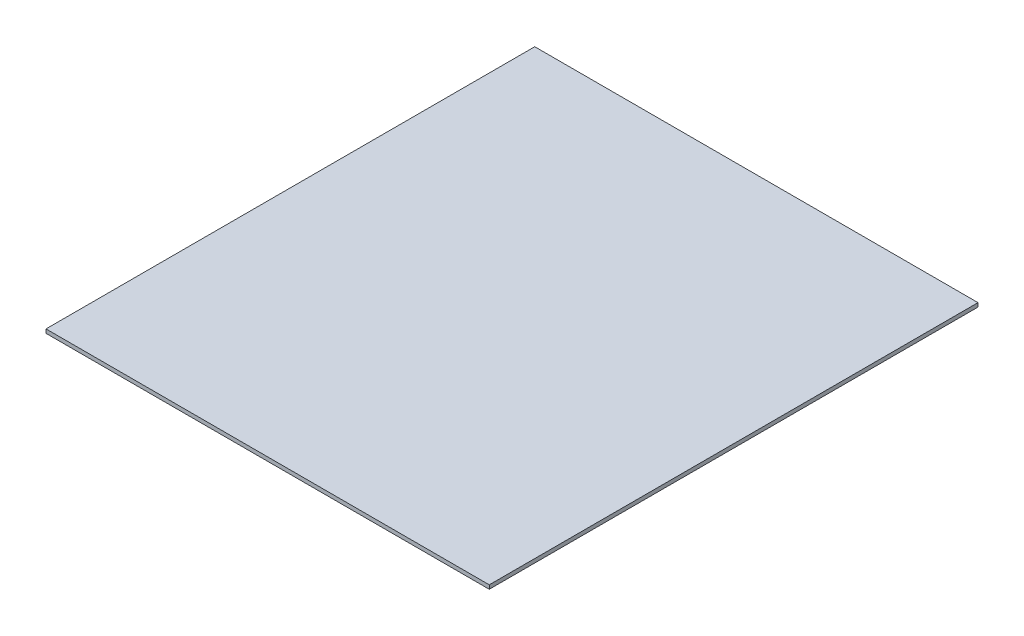
from build123d import *

# Parameters (mm, degrees)
SKETCH1_W           = 458
SKETCH1_H           = 505
BOSS_EXTRUDE1_DEPTH = 4


with BuildPart() as part:
    # Sketch1 → Boss-Extrude1 (new body)
    with BuildSketch(Plane(origin=(0, 0, 0), x_dir=(1, 0, 0), z_dir=(0, 1, 0))):
        with Locations((229, 252.5)):
            Rectangle(SKETCH1_W, SKETCH1_H)
    extrude(amount=BOSS_EXTRUDE1_DEPTH)


solid = part.part
